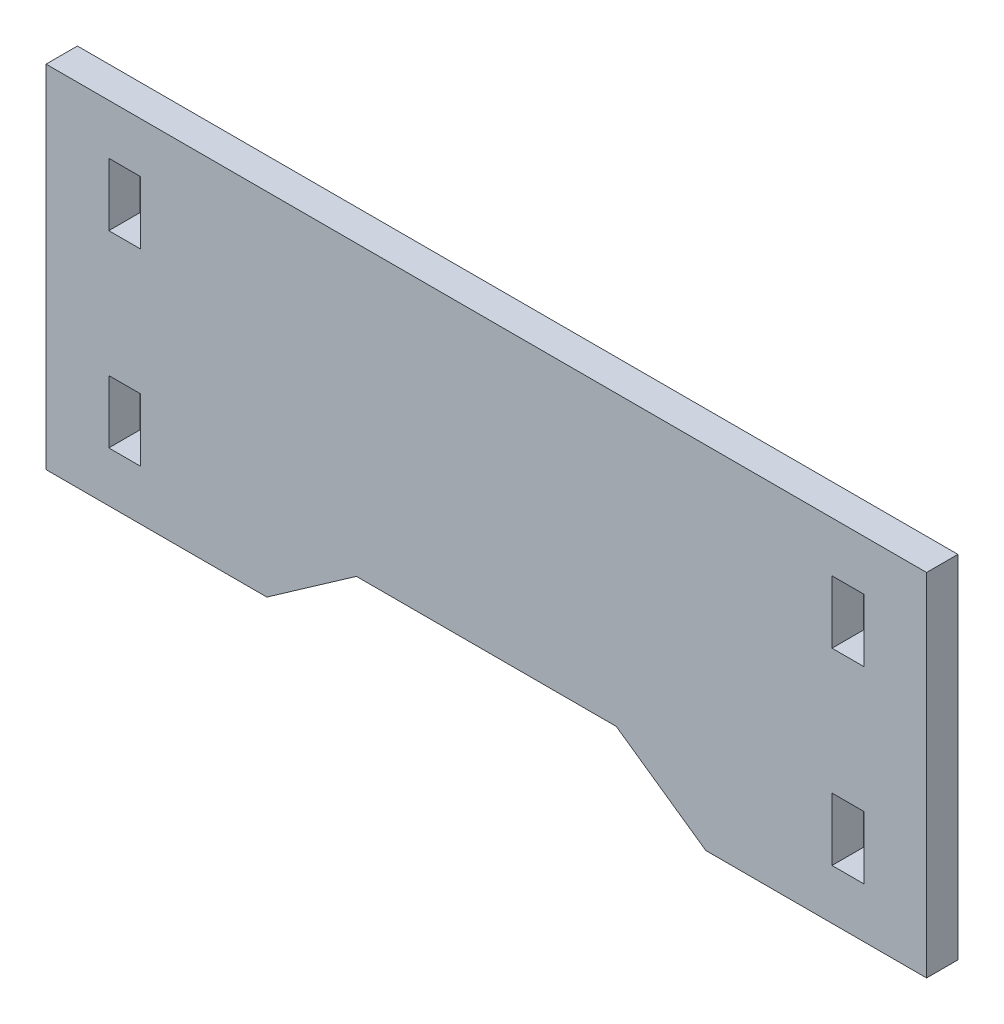
from build123d import *

# Parameters (mm, degrees)
SKETCH1_W           = 89.154
SKETCH1_H           = 35.56
BOSS_EXTRUDE1_DEPTH = 3.175
SKETCH2_W           = 3.2258
SKETCH2_H           = 6.35
CUT_EXTRUDE1_DEPTH  = 4.175
CUT_EXTRUDE2_DEPTH  = 4.175


with BuildPart() as part:
    # Sketch1 → Boss-Extrude1 (new body)
    with BuildSketch(Plane.XY):
        Rectangle(SKETCH1_W, SKETCH1_H)
    extrude(amount=BOSS_EXTRUDE1_DEPTH)

    # Sketch2 → Cut-Extrude1 (cut, through all)
    with BuildSketch(Plane.XY.offset(3.175)):
        with Locations((-36.6141, 9.525)):
            Rectangle(SKETCH2_W, SKETCH2_H)
        with Locations((-36.6141, -9.525)):
            Rectangle(SKETCH2_W, SKETCH2_H)
    cut_extrude1 = extrude(amount=-CUT_EXTRUDE1_DEPTH, mode=Mode.SUBTRACT)

    # Mirror1: Cut-Extrude1 across plane
    add(cut_extrude1.mirror(Plane(origin=(0, 0, 0), x_dir=(0, 0, 1), z_dir=(1, 0, 0))), mode=Mode.SUBTRACT)

    # Sketch3 → Cut-Extrude2 (cut, through all)
    with BuildSketch(Plane.XY.offset(3.175)):
        Polygon((-13.156260157, -11.43), (13.156260157, -11.43), (22.225, -17.78), (-22.225, -17.78), align=None)
    extrude(amount=-CUT_EXTRUDE2_DEPTH, mode=Mode.SUBTRACT)


solid = part.part
